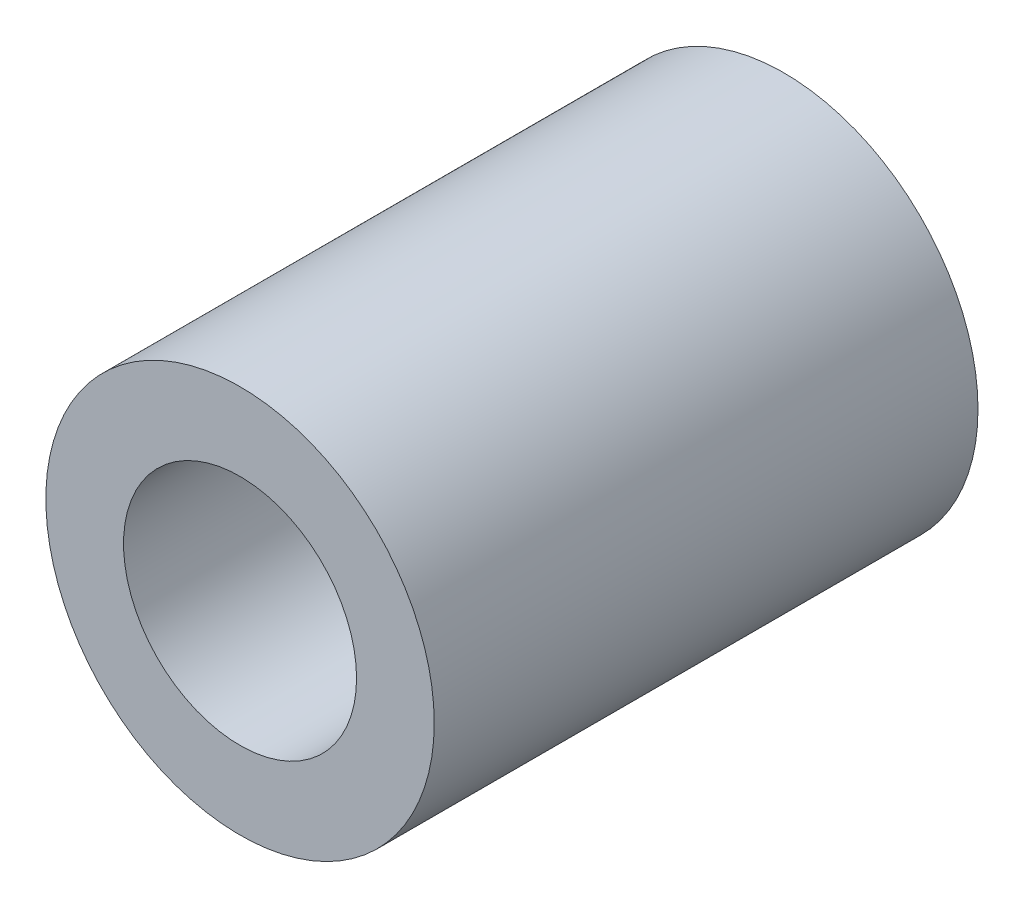
from build123d import *

# Parameters (mm, degrees)
SKETCH2_R           = 2.5
SKETCH2_R_2         = 1.5
BOSS_EXTRUDE1_DEPTH = 7


with BuildPart() as part:
    # Sketch2 → Boss-Extrude1 (new body)
    with BuildSketch(Plane.XY):
        Circle(SKETCH2_R)
        Circle(SKETCH2_R_2, mode=Mode.SUBTRACT)
    extrude(amount=BOSS_EXTRUDE1_DEPTH)


solid = part.part
